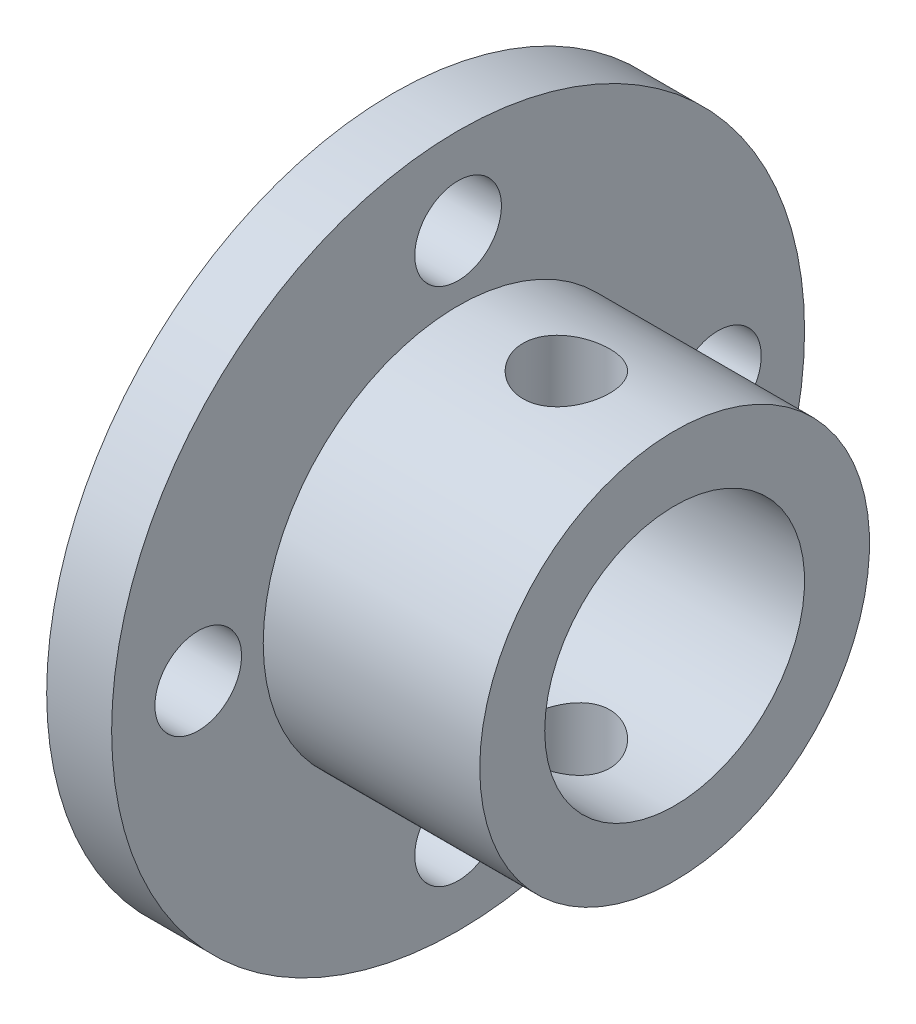
from build123d import *

# Parameters (mm, degrees)
SKETCH2_R               = 2
CUT_EXTRUDE1_DEPTH      = 14
SKETCH3_R               = 2
CUT_EXTRUDE2_DEPTH      = 17
CUT_EXTRUDE2_DEPTH_BACK = 17


with BuildPart() as part:
    # Sketch1 → Revolve1 (revolve)
    with BuildSketch(Plane.XY):
        Polygon((0, 6), (0, 16), (3, 16), (3, 9), (13, 9), (13, 6), align=None)
    revolve(axis=Axis((0, 0, 0), (1, 0, 0)))

    # Sketch2 → Cut-Extrude1 (cut, through all)
    with BuildSketch(Plane.ZY):
        with Locations((0, 12)):
            Circle(SKETCH2_R)
        with Locations((12, 0)):
            Circle(SKETCH2_R)
        with Locations((0, -12)):
            Circle(SKETCH2_R)
        with Locations((-12, 0)):
            Circle(SKETCH2_R)
    extrude(amount=-CUT_EXTRUDE1_DEPTH, mode=Mode.SUBTRACT)

    # Sketch3 → Cut-Extrude2 (cut, two sides)
    with BuildSketch(Plane(origin=(0, 0, 0), x_dir=(1, 0, 0), z_dir=(0, 1, 0))) as cut_extrude2_sk:
        with Locations((8, 0)):
            Circle(SKETCH3_R)
    extrude(amount=CUT_EXTRUDE2_DEPTH, mode=Mode.SUBTRACT)
    extrude(cut_extrude2_sk.sketch, amount=-CUT_EXTRUDE2_DEPTH_BACK, mode=Mode.SUBTRACT)


solid = part.part
